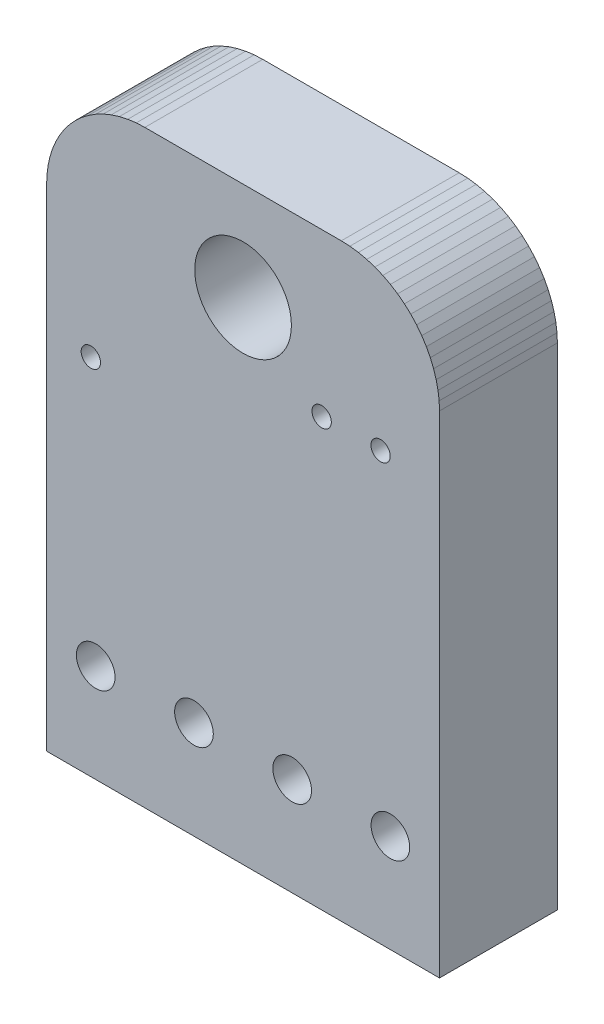
from build123d import *

# Parameters (mm, degrees)
MODEL_R             = 1.230314961
MODEL_R_2           = 0.492125984
MODEL_R_3           = 0.246062992
BOSS_EXTRUDE1_DEPTH = 3


with BuildPart() as part:
    # Model → Boss-Extrude1 (new body)
    with BuildSketch(Plane.XY):
        Polygon((0, 0), (10, 0), (10, 12.5), (9.99048659, 12.71788878), (9.962020177, 12.93411971), (9.914816068, 13.147047244), (9.849231053, 13.355050443), (9.765769562, 13.556545276), (9.665062131, 13.75), (9.547880782, 13.933941314), (9.415111344, 14.106969734), (9.267765748, 14.267765748), (9.106969734, 14.415111344), (8.933941314, 14.547880782), (8.75, 14.665062131), (8.556545276, 14.765769562), (8.355050443, 14.849231053), (8.147047244, 14.914816068), (7.93411971, 14.962020177), (7.71788878, 14.99048659), (7.5, 15), (2.5, 15), (2.28211122, 14.99048659), (2.06588029, 14.962020177), (1.852952756, 14.914816068), (1.644949557, 14.849231053), (1.443454724, 14.765769562), (1.25, 14.665062131), (1.066058686, 14.547880782), (0.893030266, 14.415111344), (0.732234252, 14.267765748), (0.584888656, 14.106969734), (0.452119218, 13.933941314), (0.334937869, 13.75), (0.234230438, 13.556545276), (0.150768947, 13.355050443), (0.085183932, 13.147047244), (0.037979823, 12.93411971), (0.00951341, 12.71788878), (0, 12.5), align=None)
        with Locations((5, 12.5)):
            Circle(MODEL_R, mode=Mode.SUBTRACT)
        with Locations((8.75, 2.5)):
            Circle(MODEL_R_2, mode=Mode.SUBTRACT)
        with Locations((6.25, 2.5)):
            Circle(MODEL_R_2, mode=Mode.SUBTRACT)
        with Locations((3.75, 2.5)):
            Circle(MODEL_R_2, mode=Mode.SUBTRACT)
        with Locations((1.25, 2.5)):
            Circle(MODEL_R_2, mode=Mode.SUBTRACT)
        with Locations((1.125, 9.25)):
            Circle(MODEL_R_3, mode=Mode.SUBTRACT)
        with Locations((8.5, 10.875)):
            Circle(MODEL_R_3, mode=Mode.SUBTRACT)
        with Locations((7, 10.875)):
            Circle(MODEL_R_3, mode=Mode.SUBTRACT)
    extrude(amount=BOSS_EXTRUDE1_DEPTH)


solid = part.part
